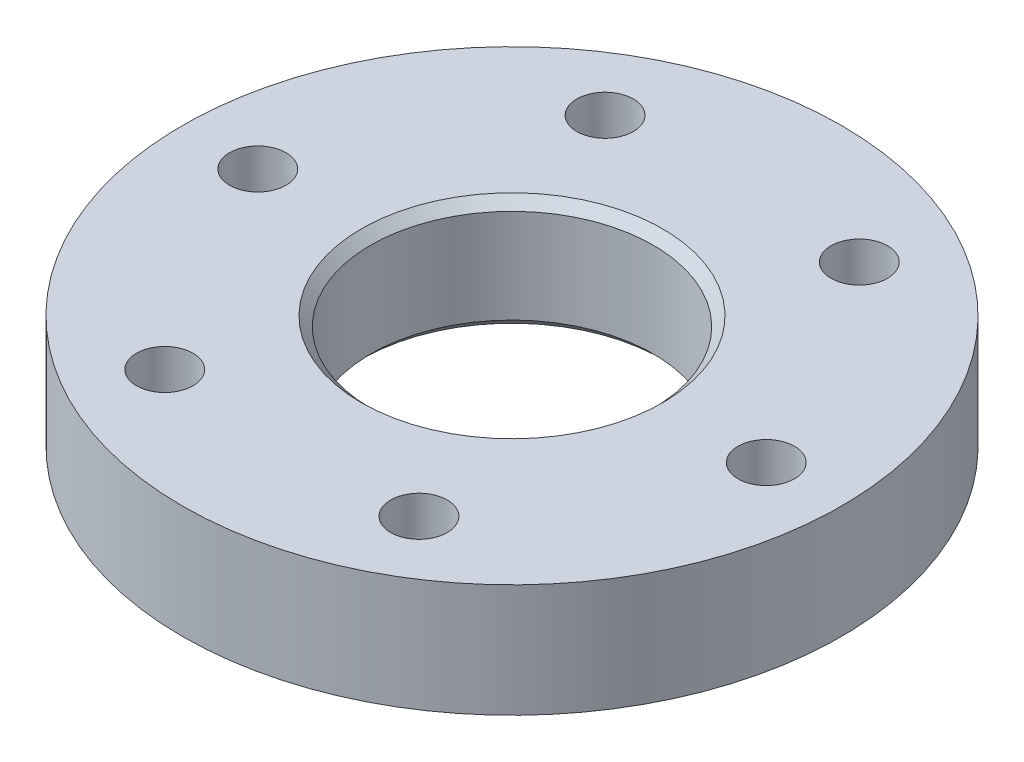
from build123d import *

# Parameters (mm, degrees)
SKETCH1_R           = 17.5
SKETCH1_R_2         = 1.5
SKETCH1_R_3         = 7.5
BOSS_EXTRUDE1_DEPTH = 3
SKETCH3_R           = 15
SKETCH3_R_2         = 12
BOSS_EXTRUDE2_DEPTH = 1.5
CHAMFER1_SIZE       = 0.5


with BuildPart() as part:
    # Sketch1 → Boss-Extrude1 (new body, symmetric)
    with BuildSketch(Plane(origin=(0, 0, 0), x_dir=(1, 0, 0), z_dir=(0, 1, 0))):
        Circle(SKETCH1_R)
        with Locations((13.5, 0)):
            Circle(SKETCH1_R_2, mode=Mode.SUBTRACT)
        with Locations((6.75, -11.691342951)):
            Circle(SKETCH1_R_2, mode=Mode.SUBTRACT)
        with Locations((-6.75, -11.691342951)):
            Circle(SKETCH1_R_2, mode=Mode.SUBTRACT)
        with Locations((-13.5, 0)):
            Circle(SKETCH1_R_2, mode=Mode.SUBTRACT)
        with Locations((-6.75, 11.691342951)):
            Circle(SKETCH1_R_2, mode=Mode.SUBTRACT)
        with Locations((6.75, 11.691342951)):
            Circle(SKETCH1_R_2, mode=Mode.SUBTRACT)
        Circle(SKETCH1_R_3, mode=Mode.SUBTRACT)
    extrude(amount=BOSS_EXTRUDE1_DEPTH, both=True)

    # Sketch3 → Boss-Extrude2 (add)
    with BuildSketch(Plane.XZ.offset(3)):
        Circle(SKETCH3_R)
        Circle(SKETCH3_R_2, mode=Mode.SUBTRACT)
    extrude(amount=-BOSS_EXTRUDE2_DEPTH)

    # Chamfer1
    chamfer1_edges = [part.edges().sort_by_distance(p)[0] for p in [
        (-7.5, -3, 0),
        (-7.5, 3, 0),
    ]]
    chamfer(chamfer1_edges, length=CHAMFER1_SIZE)


solid = part.part
